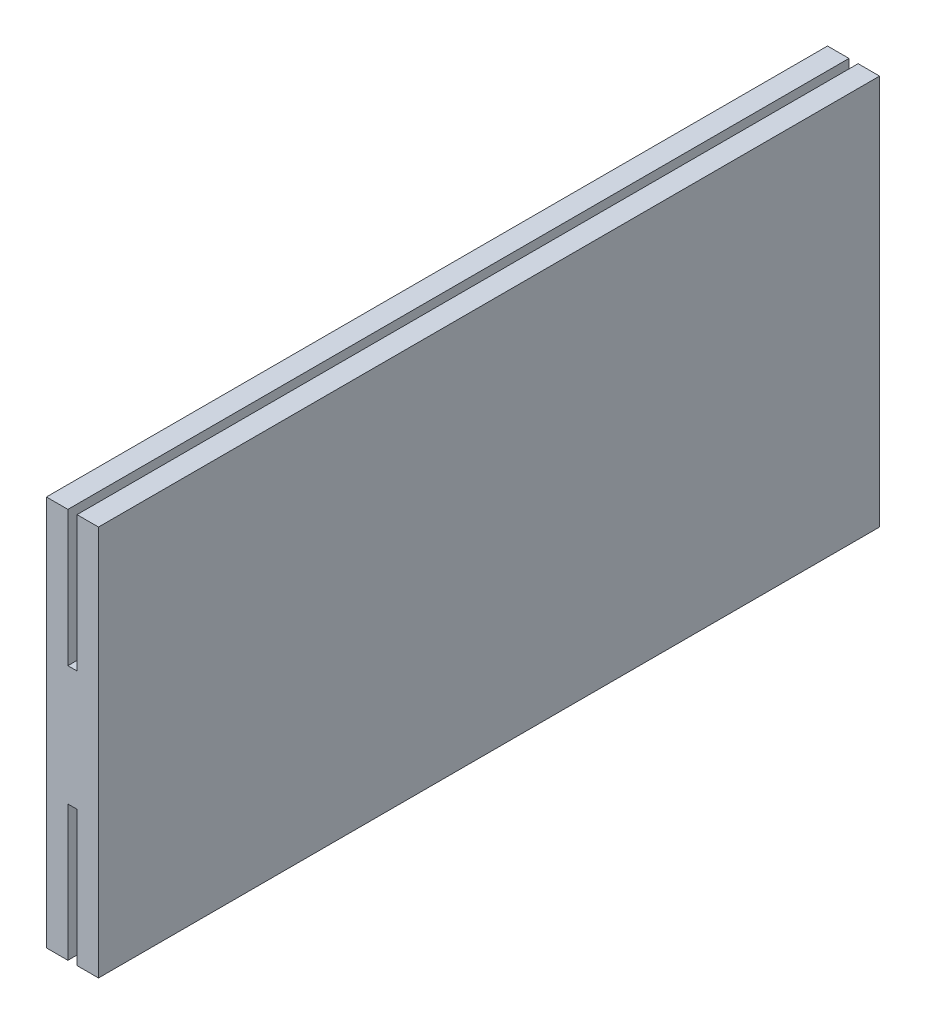
from build123d import *

# Parameters (mm, degrees)
BOSS_EXTRUDE1_DEPTH = 30


with BuildPart() as part:
    # Sketch1 → Boss-Extrude1 (new body)
    with BuildSketch(Plane.XY):
        Polygon((-0.175, 7.5), (-1, 7.5), (-1, -7.5), (-0.175, -7.5), (-0.175, -2.3), (0.175, -2.3), (0.175, -7.5), (1, -7.5), (1, 7.5), (0.175, 7.5), (0.175, 2.3), (-0.175, 2.3), align=None)
    extrude(amount=BOSS_EXTRUDE1_DEPTH)


solid = part.part
